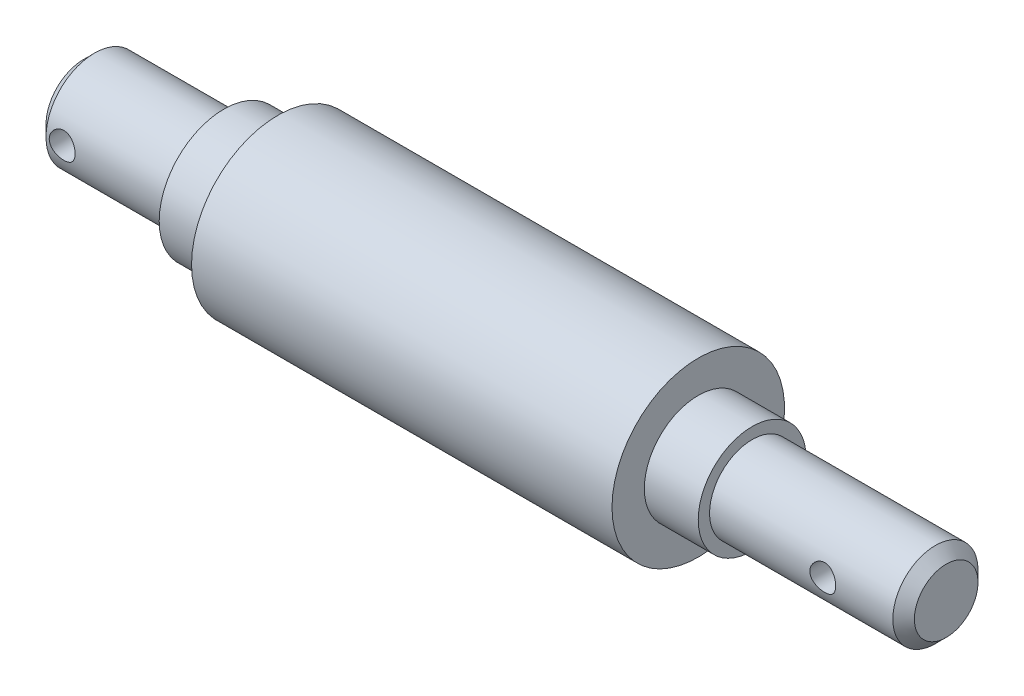
from build123d import *

# Parameters (mm, degrees)
CHAMFER1_SIZE           = 1
SKETCH2_R               = 1.2
CUT_EXTRUDE1_DEPTH      = 9
CUT_EXTRUDE1_DEPTH_BACK = 9


with BuildPart() as part:
    # Sketch1 → Revolve1 (revolve)
    with BuildSketch(Plane.XY):
        Polygon((-41.319098712, 0), (-41.319098712, 4.5), (-28.333497823, 4.5), (-28.319098712, 5.999930887), (-23.319098712, 5.999930887), (-23.319098712, 8), (15.680901288, 8), (15.680901288, 5), (20.680901288, 5), (20.680901288, 3.95), (38.680901288, 3.95), (38.680901288, 0), align=None)
    revolve(axis=Axis((-41.319098712, 0, 0), (1, 0, 0)))

    # Chamfer1
    chamfer1_edges = [part.edges().sort_by_distance(p)[0] for p in [
        (-41.319098712, -4.5, 0),
        (38.680901288, -3.95, 0),
    ]]
    chamfer(chamfer1_edges, length=CHAMFER1_SIZE)

    # Sketch2 → Cut-Extrude1 (cut, two sides)
    with BuildSketch(Plane.XY) as cut_extrude1_sk:
        with Locations((-38.819098712, 0)):
            Circle(SKETCH2_R)
        with Locations((31.180901288, 0)):
            Circle(SKETCH2_R)
    extrude(amount=CUT_EXTRUDE1_DEPTH, mode=Mode.SUBTRACT)
    extrude(cut_extrude1_sk.sketch, amount=-CUT_EXTRUDE1_DEPTH_BACK, mode=Mode.SUBTRACT)


solid = part.part
